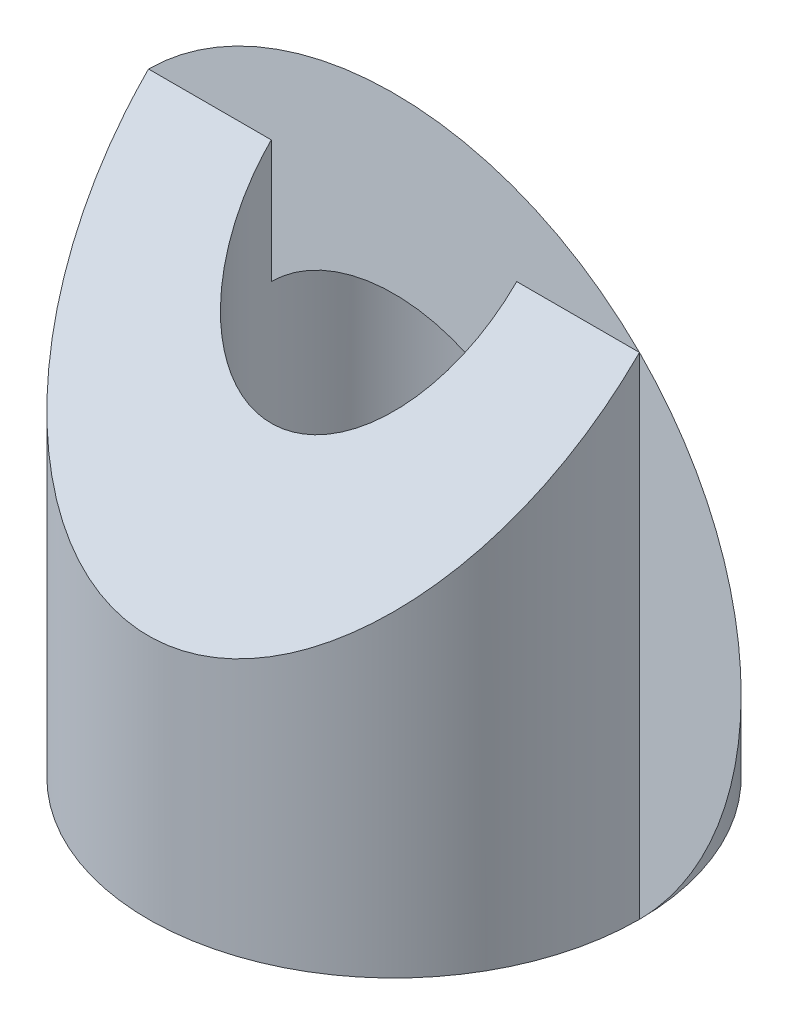
from build123d import *

# Parameters (mm, degrees)
SKETCH1_R           = 2
SKETCH1_R_2         = 1
BOSS_EXTRUDE1_DEPTH = 4
CUT_EXTRUDE1_DEPTH  = 2
CUT_EXTRUDE2_DEPTH  = 10


with BuildPart() as part:
    # Sketch1 → Boss-Extrude1 (new body)
    with BuildSketch(Plane(origin=(0, 0, 0), x_dir=(1, 0, 0), z_dir=(0, 1, 0))):
        Circle(SKETCH1_R)
        Circle(SKETCH1_R_2, mode=Mode.SUBTRACT)
    extrude(amount=BOSS_EXTRUDE1_DEPTH)

    # Sketch2 → Cut-Extrude1 (cut, symmetric)
    with BuildSketch(Plane(origin=(0, 0, 0), x_dir=(0, 0, -1), z_dir=(1, 0, 0))):
        Polygon((-2, 4), (-2, 2), (0, 4), align=None)
        Polygon((0, 4), (-2, 4), (-2, 2), align=None)
    extrude(amount=CUT_EXTRUDE1_DEPTH, both=True, mode=Mode.SUBTRACT)

    # Sketch3 → Cut-Extrude2 (cut)
    with BuildSketch(Plane.XY):
        Polygon((2, 0), (-2, 4), (2, 4), align=None)
    extrude(amount=-CUT_EXTRUDE2_DEPTH, mode=Mode.SUBTRACT)


solid = part.part
